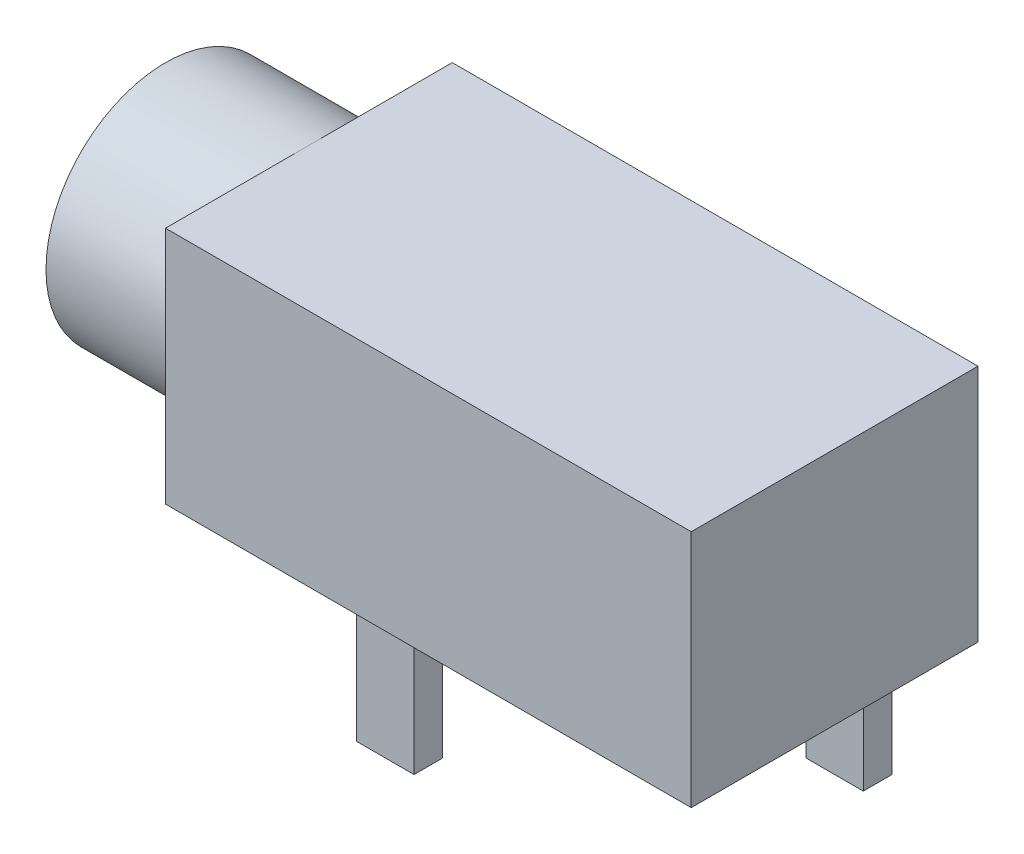
from build123d import *

# Parameters (mm, degrees)
SKETCH1_W           = 11
SKETCH1_H           = 6
BOSS_EXTRUDE1_DEPTH = 5
SKETCH2_R           = 2.5
BOSS_EXTRUDE2_DEPTH = 3
SKETCH3_W           = 1.2
SKETCH3_H           = 0.6
BOSS_EXTRUDE3_DEPTH = 2.8


with BuildPart() as part:
    # Sketch1 → Boss-Extrude1 (new body)
    with BuildSketch(Plane(origin=(0, 0, 0), x_dir=(1, 0, 0), z_dir=(0, 1, 0))):
        with Locations((5.5, -3)):
            Rectangle(SKETCH1_W, SKETCH1_H)
    extrude(amount=BOSS_EXTRUDE1_DEPTH)

    # Sketch2 → Boss-Extrude2 (add)
    with BuildSketch(Plane.ZY):
        with Locations((3, 2.5)):
            Circle(SKETCH2_R)
    extrude(amount=BOSS_EXTRUDE2_DEPTH)

    # Sketch3 → Boss-Extrude3 (add)
    with BuildSketch(Plane(origin=(0, 0, 0), x_dir=(-1, 0, 0), z_dir=(0, -1, 0))):
        with Locations((-2.1, -0.8)):
            Rectangle(SKETCH3_W, SKETCH3_H)
        with Locations((-9.1, -0.8)):
            Rectangle(SKETCH3_W, SKETCH3_H)
        with Locations((-4.1, -5.2)):
            Rectangle(SKETCH3_W, SKETCH3_H)
    extrude(amount=BOSS_EXTRUDE3_DEPTH)


solid = part.part
